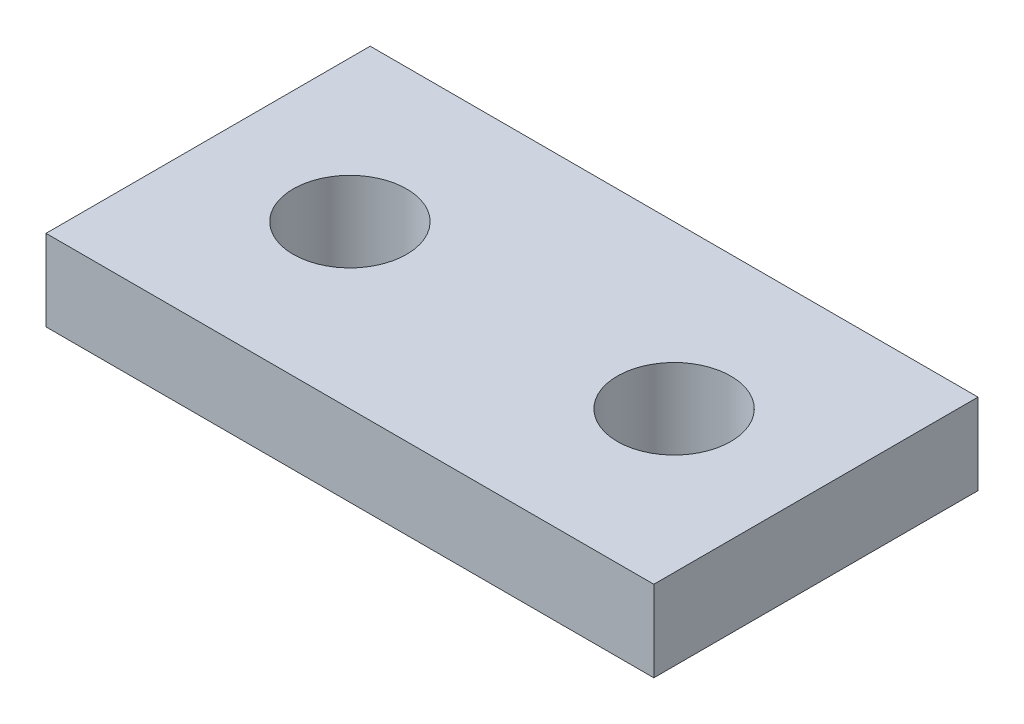
from build123d import *

# Parameters (mm, degrees)
SKETCH1_W           = 19.05
SKETCH1_H           = 10.16
SKETCH1_R           = 1.778
BOSS_EXTRUDE1_DEPTH = 2.54


with BuildPart() as part:
    # Sketch1 → Boss-Extrude1 (new body)
    with BuildSketch(Plane(origin=(0, 0, 0), x_dir=(1, 0, 0), z_dir=(0, 1, 0))):
        with Locations((0, 5.08)):
            Rectangle(SKETCH1_W, SKETCH1_H)
        with Locations((-5.08, 5.08)):
            Circle(SKETCH1_R, mode=Mode.SUBTRACT)
        with Locations((5.08, 5.08)):
            Circle(SKETCH1_R, mode=Mode.SUBTRACT)
    extrude(amount=BOSS_EXTRUDE1_DEPTH)


solid = part.part
